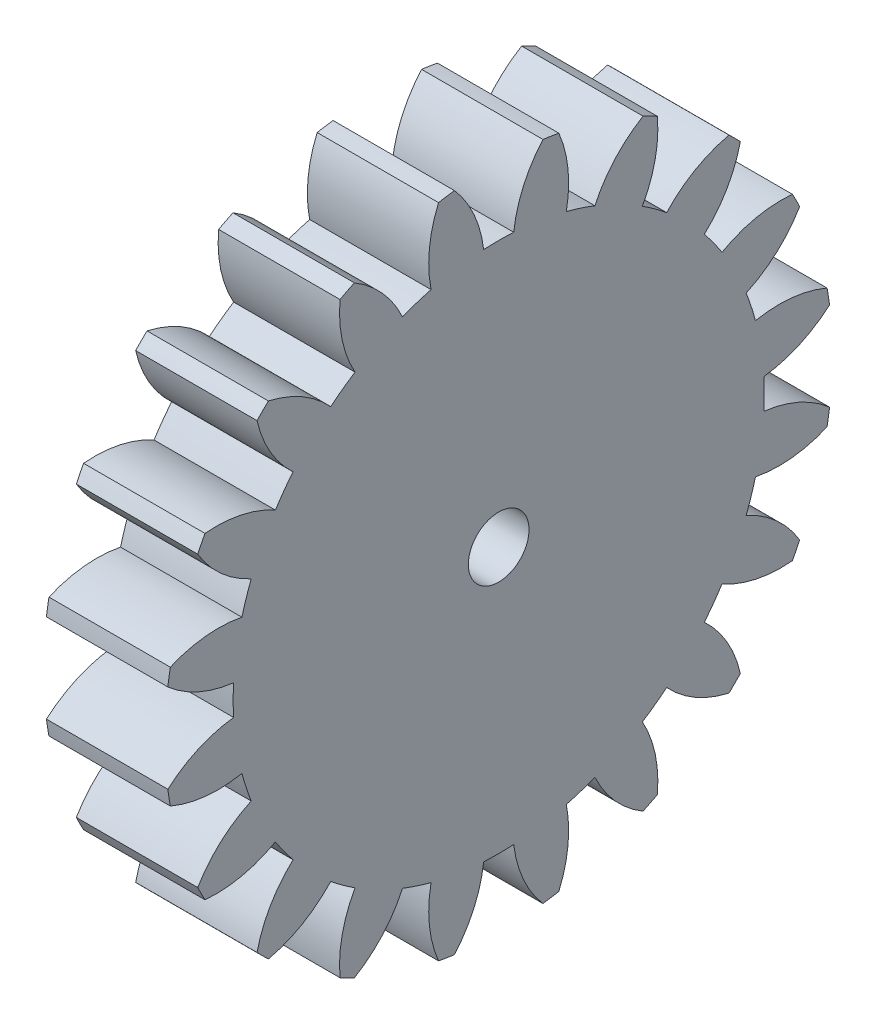
from build123d import *

# Parameters (mm, degrees)
BASPROSKE_W     = 10
BASPROSKE_H     = 27.5
TOOTHCUT_DEPTH  = 41.155946011
TEETHCUTS_COUNT = 20
TEETHCUTS_ANGLE = 342
BORSKE_R        = 2.5
BORE_DEPTH      = 50.0000508


with BuildPart() as part:
    # BasProSke → Base-Revolve (revolve)
    with BuildSketch(Plane(origin=(0, 0, 0), x_dir=(1, 0, 0), z_dir=(0, 1, 0)), mode=Mode.PRIVATE) as base_revolve_sk:
        with Locations((5, 13.75)):
            Rectangle(BASPROSKE_W, BASPROSKE_H)
    revolve(base_revolve_sk.sketch.rotate(Axis((-10, 0, 0), (1, 0, 0)), 180), axis=Axis((-10, 0, 0), (1, 0, 0)))

    # TooCutSke → ToothCut (cut, through all)
    with BuildSketch(Plane(origin=(0, 0, 0), x_dir=(0, 0, -1), z_dir=(1, 0, 0))):
        with BuildLine():
            ThreePointArc((1.237725267, 21.838954008), (0, 21.874), (-1.237725267, 21.838954008))
            ThreePointArc((-1.237725267, 21.838954008), (-2.037783758, 24.744650423), (-3.667234079, 27.280011719))
            ThreePointArc((-3.667234079, 27.280011719), (0, 27.5254), (3.667234079, 27.280011719))
            ThreePointArc((3.667234079, 27.280011719), (2.037783758, 24.744650423), (1.237725267, 21.838954008))
        make_face()
    toothcut = extrude(amount=TOOTHCUT_DEPTH, mode=Mode.SUBTRACT)

    # TeethCuts: ToothCut ×20 about axis
    teethcuts_axis = Axis((-10, 0, 0), (1, 0, 0))
    for i in range(1, TEETHCUTS_COUNT):
        add(toothcut.rotate(teethcuts_axis, i * TEETHCUTS_ANGLE / (TEETHCUTS_COUNT - 1)), mode=Mode.SUBTRACT)

    # BorSke → Bore (cut, symmetric)
    with BuildSketch(Plane(origin=(0, 0, 0), x_dir=(0, 0, -1), z_dir=(1, 0, 0))):
        with Locations(Location((0, 0, 0), (0, 0, 180))):
            Circle(BORSKE_R)
    extrude(amount=BORE_DEPTH, both=True, mode=Mode.SUBTRACT)


solid = part.part
